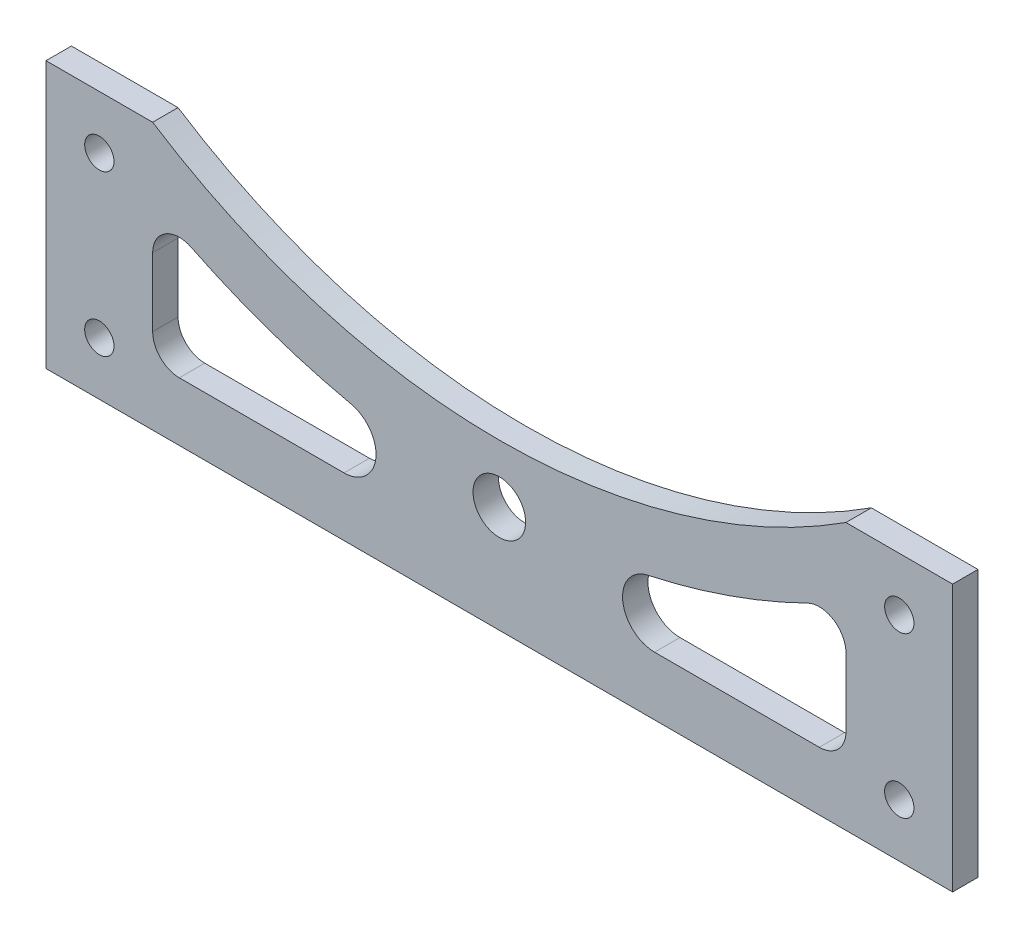
from build123d import *

# Parameters (mm, degrees)
SKETCH1_R           = 4.93
SKETCH1_R_2         = 2.75
BOSS_EXTRUDE1_DEPTH = 4.7625


with BuildPart() as part:
    # Sketch1 → Boss-Extrude1 (new body)
    with BuildSketch(Plane.XY):
        with BuildLine():
            Line((-85, 0), (85, 0))
            Line((85, 0), (85, 50))
            Line((85, 50), (65, 50))
            ThreePointArc((65, 50), (0, 30.871205009), (-65, 50))
            Line((-65, 50), (-85, 50))
            Line((-85, 50), (-85, 0))
        make_face()
        with Locations((0, 20)):
            Circle(SKETCH1_R, mode=Mode.SUBTRACT)
        with Locations((-75, 40)):
            Circle(SKETCH1_R_2, mode=Mode.SUBTRACT)
        with Locations((-75, 10)):
            Circle(SKETCH1_R_2, mode=Mode.SUBTRACT)
        with Locations((75, 40)):
            Circle(SKETCH1_R_2, mode=Mode.SUBTRACT)
        with Locations((75, 10)):
            Circle(SKETCH1_R_2, mode=Mode.SUBTRACT)
        with BuildLine():
            Line((-65, 28.82203459), (-65, 16))
            ThreePointArc((-65, 16), (-63.535533906, 12.464466094), (-60, 11))
            Line((-60, 11), (-29.111861318, 11))
            ThreePointArc((-29.111861318, 11), (-23.146216554, 16.358842801), (-27.836889289, 22.862972482))
            ThreePointArc((-27.836889289, 22.862972482), (-43.132909972, 27.17580462), (-57.794117647, 33.309136444))
            ThreePointArc((-57.794117647, 33.309136444), (-62.642970699, 33.066408028), (-65, 28.82203459))
        make_face(mode=Mode.SUBTRACT)
        with BuildLine():
            Line((65, 28.82203459), (65, 16))
            ThreePointArc((65, 16), (63.535533906, 12.464466094), (60, 11))
            Line((60, 11), (29.111861318, 11))
            ThreePointArc((29.111861318, 11), (23.146216554, 16.358842801), (27.836889289, 22.862972482))
            ThreePointArc((27.836889289, 22.862972482), (43.132909972, 27.17580462), (57.794117647, 33.309136444))
            ThreePointArc((57.794117647, 33.309136444), (62.642970699, 33.066408028), (65, 28.82203459))
        make_face(mode=Mode.SUBTRACT)
    extrude(amount=BOSS_EXTRUDE1_DEPTH)


solid = part.part
